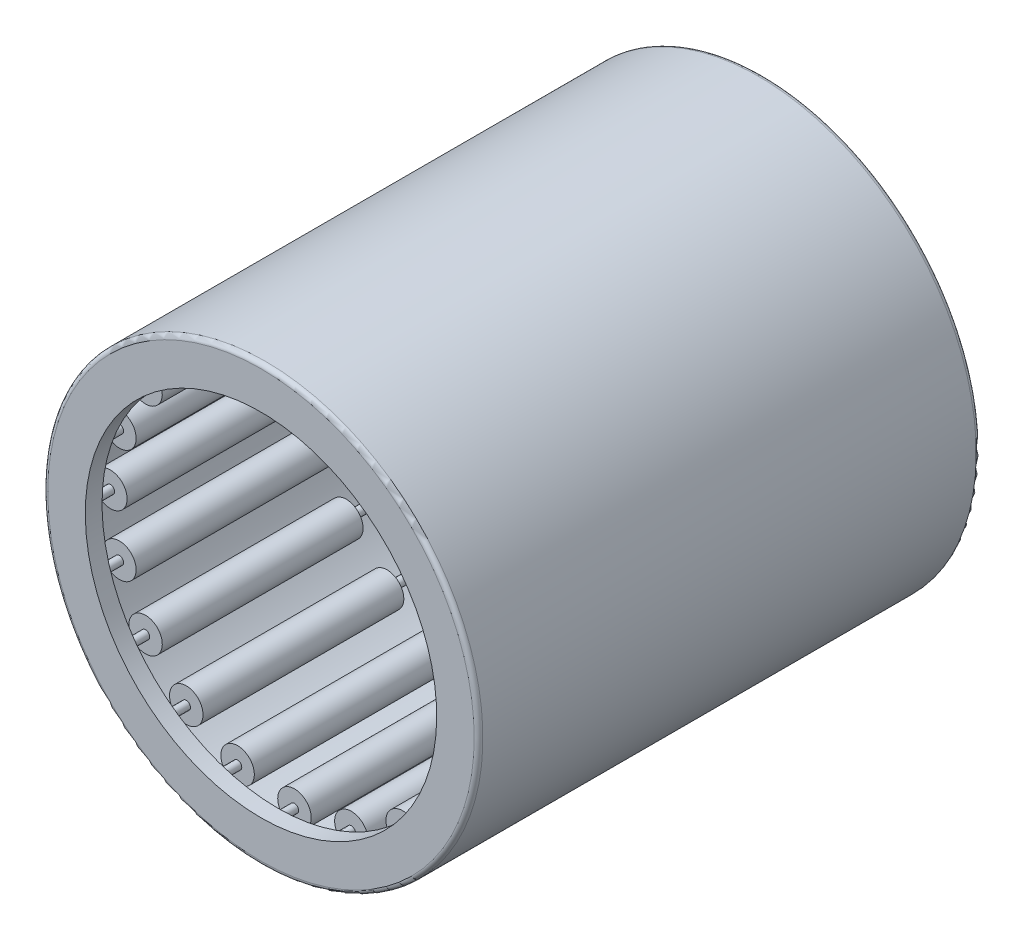
from build123d import *

# Parameters (mm, degrees)
SKETCH2_W         = 12
SKETCH2_H         = 0.75
SKETCH3_W         = 28
SKETCH3_H         = 0.25
CIRPATTERN1_COUNT = 20
CIRPATTERN1_ANGLE = 342
FILLET1_R         = 0.26


with BuildPart() as part:
    # Sketch1 → Revolve1 (revolve)
    with BuildSketch(Plane(origin=(0, 0, 0), x_dir=(0, 0, -1), z_dir=(1, 0, 0))):
        Polygon((-15, 13), (15, 13), (15, 10.5), (14, 10.5), (14, 12), (-14, 12), (-14, 10.5), (-15, 10.5), align=None)
    revolve(axis=Axis((0, 0, 15), (0, 0, -1)))

    # Fillet1
    fillet1_edges = [part.edges().sort_by_distance(p)[0] for p in [
        (0, -13, -15),
        (0, -13, 15),
    ]]
    fillet(fillet1_edges, radius=FILLET1_R)


with BuildPart() as body_2:
    # Sketch2 → Revolve2 (revolve)
    with BuildSketch(Plane(origin=(0, 0, 0), x_dir=(0, 0, -1), z_dir=(1, 0, 0))):
        with Locations((-7, 11.625)):
            Rectangle(SKETCH2_W, SKETCH2_H)
        with Locations((7, 11.625)):
            Rectangle(SKETCH2_W, SKETCH2_H)
    revolve(axis=Axis((0, 11, 13), (0, 0, -1)))


with BuildPart() as body_3:
    # Sketch3 → Revolve3 (revolve)
    with BuildSketch(Plane(origin=(0, 0, 0), x_dir=(0, 0, -1), z_dir=(1, 0, 0))):
        with Locations((0, 11.125)):
            Rectangle(SKETCH3_W, SKETCH3_H)
    revolve(axis=Axis((0, 11, 14), (0, 0, -1)))


with BuildPart() as cirpattern1_1:
    # CirPattern1: pattern copy
    add(body_2.part.rotate(Axis((0, 0, -15), (0, 0, 1)), 1 * CIRPATTERN1_ANGLE / (CIRPATTERN1_COUNT - 1)))


with BuildPart() as cirpattern1_2:
    # CirPattern1: pattern copy
    add(body_2.part.rotate(Axis((0, 0, -15), (0, 0, 1)), 2 * CIRPATTERN1_ANGLE / (CIRPATTERN1_COUNT - 1)))


with BuildPart() as cirpattern1_3:
    # CirPattern1: pattern copy
    add(body_2.part.rotate(Axis((0, 0, -15), (0, 0, 1)), 3 * CIRPATTERN1_ANGLE / (CIRPATTERN1_COUNT - 1)))


with BuildPart() as cirpattern1_4:
    # CirPattern1: pattern copy
    add(body_2.part.rotate(Axis((0, 0, -15), (0, 0, 1)), 4 * CIRPATTERN1_ANGLE / (CIRPATTERN1_COUNT - 1)))


with BuildPart() as cirpattern1_5:
    # CirPattern1: pattern copy
    add(body_2.part.rotate(Axis((0, 0, -15), (0, 0, 1)), 5 * CIRPATTERN1_ANGLE / (CIRPATTERN1_COUNT - 1)))


with BuildPart() as cirpattern1_6:
    # CirPattern1: pattern copy
    add(body_2.part.rotate(Axis((0, 0, -15), (0, 0, 1)), 6 * CIRPATTERN1_ANGLE / (CIRPATTERN1_COUNT - 1)))


with BuildPart() as cirpattern1_7:
    # CirPattern1: pattern copy
    add(body_2.part.rotate(Axis((0, 0, -15), (0, 0, 1)), 7 * CIRPATTERN1_ANGLE / (CIRPATTERN1_COUNT - 1)))


with BuildPart() as cirpattern1_8:
    # CirPattern1: pattern copy
    add(body_2.part.rotate(Axis((0, 0, -15), (0, 0, 1)), 8 * CIRPATTERN1_ANGLE / (CIRPATTERN1_COUNT - 1)))


with BuildPart() as cirpattern1_9:
    # CirPattern1: pattern copy
    add(body_2.part.rotate(Axis((0, 0, -15), (0, 0, 1)), 9 * CIRPATTERN1_ANGLE / (CIRPATTERN1_COUNT - 1)))


with BuildPart() as cirpattern1_10:
    # CirPattern1: pattern copy
    add(body_2.part.rotate(Axis((0, 0, -15), (0, 0, 1)), 10 * CIRPATTERN1_ANGLE / (CIRPATTERN1_COUNT - 1)))


with BuildPart() as cirpattern1_11:
    # CirPattern1: pattern copy
    add(body_2.part.rotate(Axis((0, 0, -15), (0, 0, 1)), 11 * CIRPATTERN1_ANGLE / (CIRPATTERN1_COUNT - 1)))


with BuildPart() as cirpattern1_12:
    # CirPattern1: pattern copy
    add(body_2.part.rotate(Axis((0, 0, -15), (0, 0, 1)), 12 * CIRPATTERN1_ANGLE / (CIRPATTERN1_COUNT - 1)))


with BuildPart() as cirpattern1_13:
    # CirPattern1: pattern copy
    add(body_2.part.rotate(Axis((0, 0, -15), (0, 0, 1)), 13 * CIRPATTERN1_ANGLE / (CIRPATTERN1_COUNT - 1)))


with BuildPart() as cirpattern1_14:
    # CirPattern1: pattern copy
    add(body_2.part.rotate(Axis((0, 0, -15), (0, 0, 1)), 14 * CIRPATTERN1_ANGLE / (CIRPATTERN1_COUNT - 1)))


with BuildPart() as cirpattern1_15:
    # CirPattern1: pattern copy
    add(body_2.part.rotate(Axis((0, 0, -15), (0, 0, 1)), 15 * CIRPATTERN1_ANGLE / (CIRPATTERN1_COUNT - 1)))


with BuildPart() as cirpattern1_16:
    # CirPattern1: pattern copy
    add(body_2.part.rotate(Axis((0, 0, -15), (0, 0, 1)), 16 * CIRPATTERN1_ANGLE / (CIRPATTERN1_COUNT - 1)))


with BuildPart() as cirpattern1_17:
    # CirPattern1: pattern copy
    add(body_2.part.rotate(Axis((0, 0, -15), (0, 0, 1)), 17 * CIRPATTERN1_ANGLE / (CIRPATTERN1_COUNT - 1)))


with BuildPart() as cirpattern1_18:
    # CirPattern1: pattern copy
    add(body_2.part.rotate(Axis((0, 0, -15), (0, 0, 1)), 18 * CIRPATTERN1_ANGLE / (CIRPATTERN1_COUNT - 1)))


with BuildPart() as cirpattern1_19:
    # CirPattern1: pattern copy
    add(body_2.part.rotate(Axis((0, 0, -15), (0, 0, 1)), 19 * CIRPATTERN1_ANGLE / (CIRPATTERN1_COUNT - 1)))


with BuildPart() as cirpattern1_20:
    # CirPattern1: pattern copy
    add(body_3.part.rotate(Axis((0, 0, -15), (0, 0, 1)), 1 * CIRPATTERN1_ANGLE / (CIRPATTERN1_COUNT - 1)))


with BuildPart() as cirpattern1_21:
    # CirPattern1: pattern copy
    add(body_3.part.rotate(Axis((0, 0, -15), (0, 0, 1)), 2 * CIRPATTERN1_ANGLE / (CIRPATTERN1_COUNT - 1)))


with BuildPart() as cirpattern1_22:
    # CirPattern1: pattern copy
    add(body_3.part.rotate(Axis((0, 0, -15), (0, 0, 1)), 3 * CIRPATTERN1_ANGLE / (CIRPATTERN1_COUNT - 1)))


with BuildPart() as cirpattern1_23:
    # CirPattern1: pattern copy
    add(body_3.part.rotate(Axis((0, 0, -15), (0, 0, 1)), 4 * CIRPATTERN1_ANGLE / (CIRPATTERN1_COUNT - 1)))


with BuildPart() as cirpattern1_24:
    # CirPattern1: pattern copy
    add(body_3.part.rotate(Axis((0, 0, -15), (0, 0, 1)), 5 * CIRPATTERN1_ANGLE / (CIRPATTERN1_COUNT - 1)))


with BuildPart() as cirpattern1_25:
    # CirPattern1: pattern copy
    add(body_3.part.rotate(Axis((0, 0, -15), (0, 0, 1)), 6 * CIRPATTERN1_ANGLE / (CIRPATTERN1_COUNT - 1)))


with BuildPart() as cirpattern1_26:
    # CirPattern1: pattern copy
    add(body_3.part.rotate(Axis((0, 0, -15), (0, 0, 1)), 7 * CIRPATTERN1_ANGLE / (CIRPATTERN1_COUNT - 1)))


with BuildPart() as cirpattern1_27:
    # CirPattern1: pattern copy
    add(body_3.part.rotate(Axis((0, 0, -15), (0, 0, 1)), 8 * CIRPATTERN1_ANGLE / (CIRPATTERN1_COUNT - 1)))


with BuildPart() as cirpattern1_28:
    # CirPattern1: pattern copy
    add(body_3.part.rotate(Axis((0, 0, -15), (0, 0, 1)), 9 * CIRPATTERN1_ANGLE / (CIRPATTERN1_COUNT - 1)))


with BuildPart() as cirpattern1_29:
    # CirPattern1: pattern copy
    add(body_3.part.rotate(Axis((0, 0, -15), (0, 0, 1)), 10 * CIRPATTERN1_ANGLE / (CIRPATTERN1_COUNT - 1)))


with BuildPart() as cirpattern1_30:
    # CirPattern1: pattern copy
    add(body_3.part.rotate(Axis((0, 0, -15), (0, 0, 1)), 11 * CIRPATTERN1_ANGLE / (CIRPATTERN1_COUNT - 1)))


with BuildPart() as cirpattern1_31:
    # CirPattern1: pattern copy
    add(body_3.part.rotate(Axis((0, 0, -15), (0, 0, 1)), 12 * CIRPATTERN1_ANGLE / (CIRPATTERN1_COUNT - 1)))


with BuildPart() as cirpattern1_32:
    # CirPattern1: pattern copy
    add(body_3.part.rotate(Axis((0, 0, -15), (0, 0, 1)), 13 * CIRPATTERN1_ANGLE / (CIRPATTERN1_COUNT - 1)))


with BuildPart() as cirpattern1_33:
    # CirPattern1: pattern copy
    add(body_3.part.rotate(Axis((0, 0, -15), (0, 0, 1)), 14 * CIRPATTERN1_ANGLE / (CIRPATTERN1_COUNT - 1)))


with BuildPart() as cirpattern1_34:
    # CirPattern1: pattern copy
    add(body_3.part.rotate(Axis((0, 0, -15), (0, 0, 1)), 15 * CIRPATTERN1_ANGLE / (CIRPATTERN1_COUNT - 1)))


with BuildPart() as cirpattern1_35:
    # CirPattern1: pattern copy
    add(body_3.part.rotate(Axis((0, 0, -15), (0, 0, 1)), 16 * CIRPATTERN1_ANGLE / (CIRPATTERN1_COUNT - 1)))


with BuildPart() as cirpattern1_36:
    # CirPattern1: pattern copy
    add(body_3.part.rotate(Axis((0, 0, -15), (0, 0, 1)), 17 * CIRPATTERN1_ANGLE / (CIRPATTERN1_COUNT - 1)))


with BuildPart() as cirpattern1_37:
    # CirPattern1: pattern copy
    add(body_3.part.rotate(Axis((0, 0, -15), (0, 0, 1)), 18 * CIRPATTERN1_ANGLE / (CIRPATTERN1_COUNT - 1)))


with BuildPart() as cirpattern1_38:
    # CirPattern1: pattern copy
    add(body_3.part.rotate(Axis((0, 0, -15), (0, 0, 1)), 19 * CIRPATTERN1_ANGLE / (CIRPATTERN1_COUNT - 1)))


solid = Compound([part.part, body_2.part, body_3.part, cirpattern1_1.part, cirpattern1_2.part, cirpattern1_3.part, cirpattern1_4.part, cirpattern1_5.part, cirpattern1_6.part, cirpattern1_7.part, cirpattern1_8.part, cirpattern1_9.part, cirpattern1_10.part, cirpattern1_11.part, cirpattern1_12.part, cirpattern1_13.part, cirpattern1_14.part, cirpattern1_15.part, cirpattern1_16.part, cirpattern1_17.part, cirpattern1_18.part, cirpattern1_19.part, cirpattern1_20.part, cirpattern1_21.part, cirpattern1_22.part, cirpattern1_23.part, cirpattern1_24.part, cirpattern1_25.part, cirpattern1_26.part, cirpattern1_27.part, cirpattern1_28.part, cirpattern1_29.part, cirpattern1_30.part, cirpattern1_31.part, cirpattern1_32.part, cirpattern1_33.part, cirpattern1_34.part, cirpattern1_35.part, cirpattern1_36.part, cirpattern1_37.part, cirpattern1_38.part])
